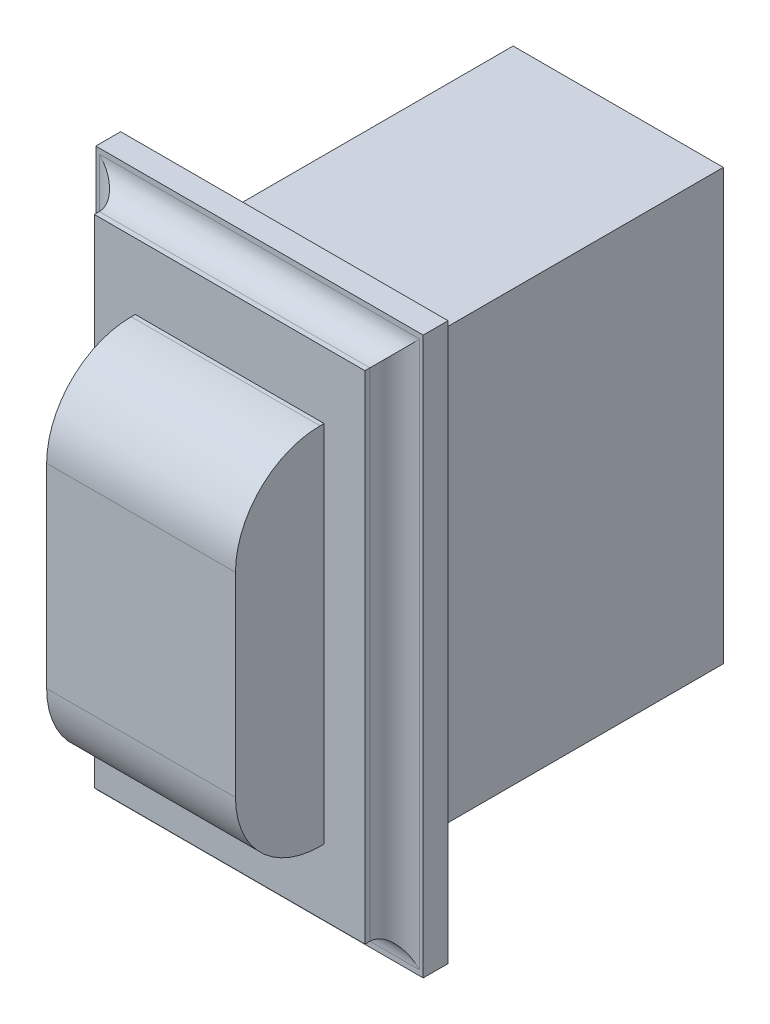
from build123d import *

# Parameters (mm, degrees)
SKETCH1_W           = 33.4264
SKETCH1_H           = 56.8452
BOSS_EXTRUDE1_DEPTH = 2.54
SKETCH2_W           = 27.6352
SKETCH2_H           = 50.6984
BOSS_EXTRUDE2_DEPTH = 3.048
SKETCH3_W           = 19.2786
SKETCH3_H           = 37.1856
BOSS_EXTRUDE3_DEPTH = 9.0424
FILLET1_R           = 2.54
FILLET7_R           = 8.636
SKETCH4_W           = 21.463
SKETCH4_H           = 43.8912
BOSS_EXTRUDE4_DEPTH = 34.0868


with BuildPart() as part:
    # Sketch1 → Boss-Extrude1 (new body)
    with BuildSketch(Plane.XY):
        Rectangle(SKETCH1_W, SKETCH1_H)
    extrude(amount=BOSS_EXTRUDE1_DEPTH)

    # Sketch2 → Boss-Extrude2 (add)
    with BuildSketch(Plane.XY.offset(2.54)):
        Rectangle(SKETCH2_W, SKETCH2_H)
    extrude(amount=BOSS_EXTRUDE2_DEPTH)

    # Sketch3 → Boss-Extrude3 (add)
    with BuildSketch(Plane.XY.offset(5.588)):
        Rectangle(SKETCH3_W, SKETCH3_H)
    extrude(amount=BOSS_EXTRUDE3_DEPTH)

    # Fillet1
    fillet1_edges = [part.edges().sort_by_distance(p)[0] for p in [
        (13.8176, 0, 2.54),
        (0, 25.3492, 2.54),
        (-13.8176, 0, 2.54),
        (0, -25.3492, 2.54),
    ]]
    fillet(fillet1_edges, radius=FILLET1_R)

    # Fillet7
    fillet7_edges = [part.edges().sort_by_distance(p)[0] for p in [
        (0, 18.5928, 14.6304),
        (0, -18.5928, 14.6304),
    ]]
    fillet(fillet7_edges, radius=FILLET7_R)

    # Sketch4 → Boss-Extrude4 (add)
    with BuildSketch(Plane(origin=(0, 0, 0), x_dir=(-1, 0, 0), z_dir=(0, 0, -1))):
        Rectangle(SKETCH4_W, SKETCH4_H)
    extrude(amount=BOSS_EXTRUDE4_DEPTH)


solid = part.part
